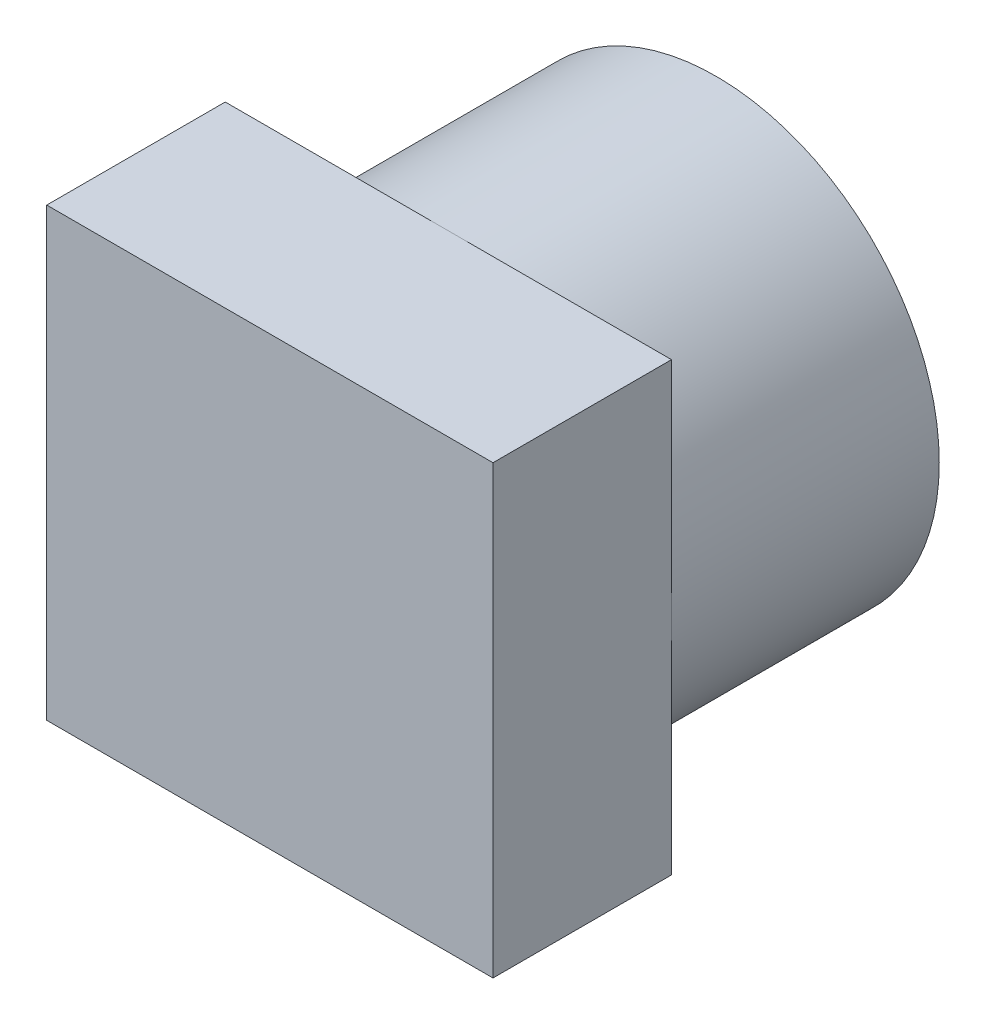
from build123d import *

# Parameters (mm, degrees)
SKETCH1_R           = 1.25
BOSS_EXTRUDE1_DEPTH = 1.5
SKETCH1_4_R         = 0.5
CUT_EXTRUDE1_DEPTH  = 1
SKETCH2_W           = 2.5
SKETCH2_H           = 2.5
BOSS_EXTRUDE2_DEPTH = 1


with BuildPart() as part:
    # Sketch1 → Boss-Extrude1 (new body)
    with BuildSketch(Plane.XY):
        Circle(SKETCH1_R)
    extrude(amount=BOSS_EXTRUDE1_DEPTH)

    # Sketch1_4 → Cut-Extrude1 (cut)
    with BuildSketch(Plane.XY):
        Circle(SKETCH1_4_R)
    extrude(amount=CUT_EXTRUDE1_DEPTH, mode=Mode.SUBTRACT)

    # Sketch2 → Boss-Extrude2 (add)
    with BuildSketch(Plane.XY.offset(1.5)):
        Rectangle(SKETCH2_W, SKETCH2_H)
    extrude(amount=BOSS_EXTRUDE2_DEPTH)


solid = part.part
